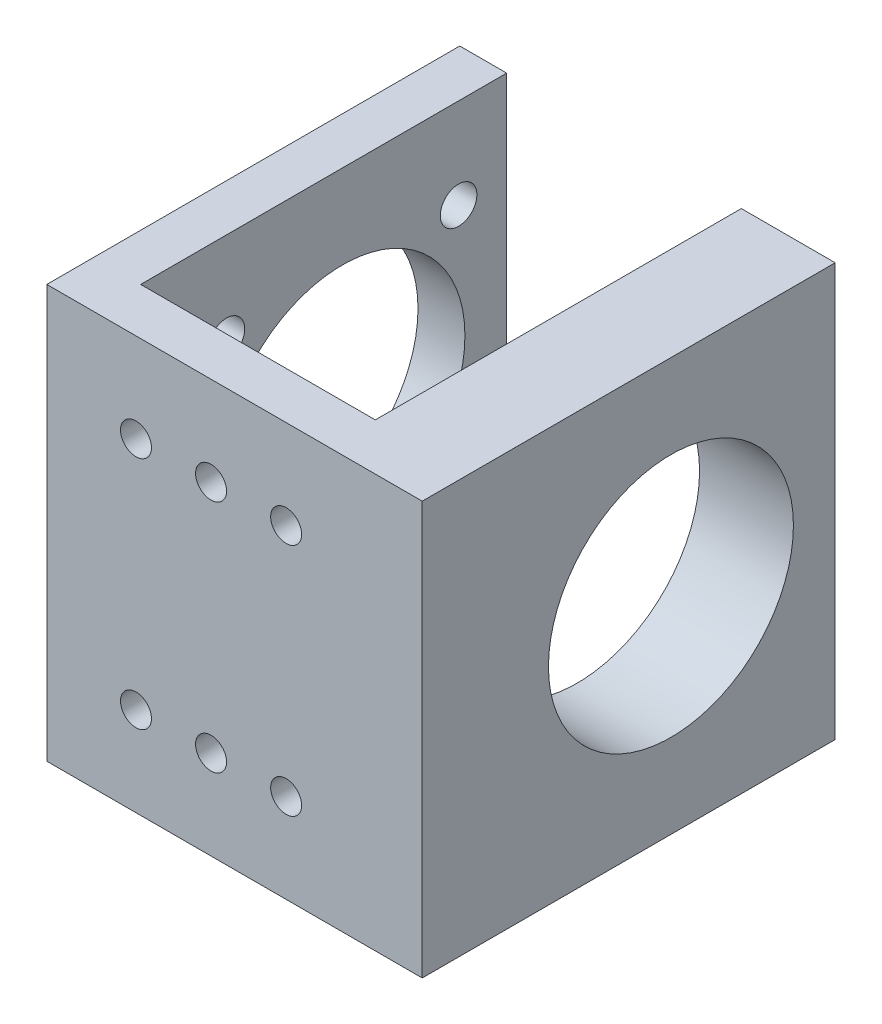
from build123d import *

# Parameters (mm, degrees)
EXTRUDE_1_DEPTH     = 44
SKETCH_3_R          = 1.65
CUT_EXTRUDE_1_DEPTH = 44
SKETCH_6_R          = 1.95
CUT_EXTRUDE_5_DEPTH = 5
SKETCH_4_R          = 13.05
CUT_EXTRUDE_6_DEPTH = 53


with BuildPart() as part:
    # 草图1 → 凸台-拉伸1 (new body)
    with BuildSketch(Plane(origin=(0, 0, 0), x_dir=(1, 0, 0), z_dir=(0, 1, 0))):
        Polygon((-47.233094812, -18.47763864), (-47.233094812, -62.47763864), (-7.233094812, -62.47763864), (-7.233094812, -18.47763864), (-17.233094812, -18.47763864), (-17.233094812, -57.47763864), (-42.233094812, -57.47763864), (-42.233094812, -18.47763864), align=None)
    extrude(amount=EXTRUDE_1_DEPTH)

    # 草图3 → 切除-拉伸1 (cut)
    with BuildSketch(Plane(origin=(0, 0, 57.47763864), x_dir=(-1, 0, 0), z_dir=(0, 0, -1))):
        with Locations((37.733094812, 34.5)):
            Circle(SKETCH_3_R)
        with Locations((37.733094812, 9.5)):
            Circle(SKETCH_3_R)
        with Locations((29.733094812, 34.5)):
            Circle(SKETCH_3_R)
        with Locations((29.733094812, 9.5)):
            Circle(SKETCH_3_R)
        with Locations((21.733094812, 34.5)):
            Circle(SKETCH_3_R)
        with Locations((21.733094812, 9.5)):
            Circle(SKETCH_3_R)
    extrude(amount=-CUT_EXTRUDE_1_DEPTH, mode=Mode.SUBTRACT)

    # 草图6 → 切除-拉伸5 (cut)
    with BuildSketch(Plane.ZY.offset(47.233094812)):
        with Locations((48.34323864, 34.375)):
            Circle(SKETCH_6_R)
        with Locations((23.60323864, 34.375)):
            Circle(SKETCH_6_R)
        with Locations((48.34323864, 9.625)):
            Circle(SKETCH_6_R)
        with Locations((23.60323864, 9.625)):
            Circle(SKETCH_6_R)
    extrude(amount=-CUT_EXTRUDE_5_DEPTH, mode=Mode.SUBTRACT)

    # 草图4 → 切除-拉伸6 (cut)
    with BuildSketch(Plane(origin=(-7.233094812, 0, 0), x_dir=(0, 0, -1), z_dir=(1, 0, 0))):
        with Locations((-35.97763864, 22)):
            Circle(SKETCH_4_R)
    extrude(amount=-CUT_EXTRUDE_6_DEPTH, mode=Mode.SUBTRACT)


solid = part.part
